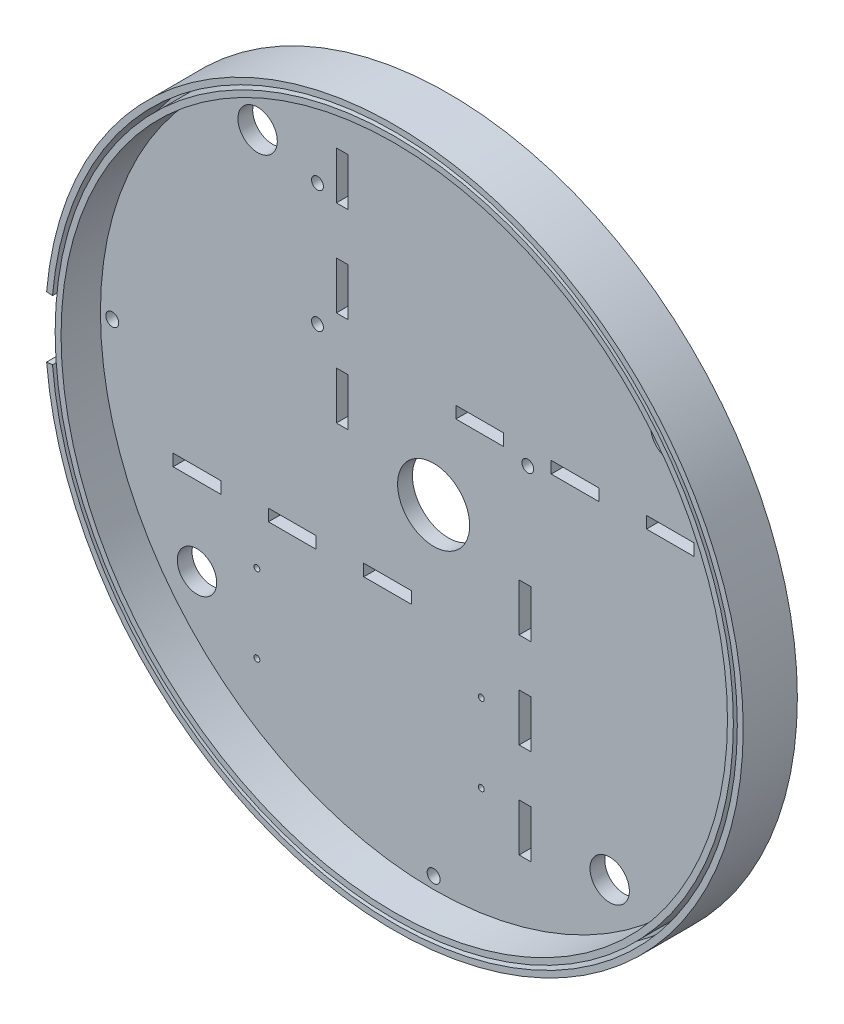
from build123d import *

# Parameters (mm, degrees)
SKETCH1_W                   = 200
SKETCH1_H                   = 200
SKETCH1_R                   = 9.15
BOSS_EXTRUDE1_DEPTH         = 3.75
SKETCH5_W                   = 12.1
SKETCH5_H                   = 3
SKETCH5_R                   = 5
CUT_EXTRUDE6_DEPTH          = 10
CIRPATTERN2_COUNT           = 4
SKETCH6_W                   = 200
SKETCH6_H                   = 200
SKETCH6_R                   = 88.610994186
CUT_EXTRUDE10_DEPTH         = 142.471065946
BOSS_EXTRUDE2_START         = 10
SKETCH7_R                   = 86.110994186
SKETCH7_R_2                 = 84.610994186
BOSS_EXTRUDE2_DEPTH         = 10
SKETCH11_R                  = 1.5
BOSS_EXTRUDE3_DEPTH         = 5
SKETCH13_R                  = 1.5
CUT_EXTRUDE11_DEPTH         = 127.066962688
SKETCH14_R                  = 0.75
BOSS_EXTRUDE4_DEPTH         = 3
SKETCH14_3_R                = 0.75
CUT_EXTRUDE12_DEPTH         = 127.066962688
TAP_DRILL_FOR_M4X0_7_TAP1_D = 3.3
CIRPATTERN3_COUNT           = 4


with BuildPart() as part:
    # Sketch1 → Boss-Extrude1 (new body)
    with BuildSketch(Plane.XY):
        Rectangle(SKETCH1_W, SKETCH1_H)
        Circle(SKETCH1_R, mode=Mode.SUBTRACT)
    extrude(amount=-BOSS_EXTRUDE1_DEPTH)

    # Sketch5 → Cut-Extrude6 (cut)
    with BuildSketch(Plane.XY):
        with Locations((11.7, 23.2)):
            Rectangle(SKETCH5_W, SKETCH5_H)
        with Locations((60.1, 23.2)):
            Rectangle(SKETCH5_W, SKETCH5_H)
        with Locations((35.9, 23.2)):
            Rectangle(SKETCH5_W, SKETCH5_H)
        with Locations((60.1, 44.7)):
            Circle(SKETCH5_R)
    cut_extrude6 = extrude(amount=-CUT_EXTRUDE6_DEPTH, mode=Mode.SUBTRACT)

    # CirPattern2: Cut-Extrude6 ×4 about axis
    cirpattern2_axis = Axis((0, 0, -3.75), (0, 0, 1))
    for i in range(1, CIRPATTERN2_COUNT):
        add(cut_extrude6.rotate(cirpattern2_axis, i * 360 / CIRPATTERN2_COUNT), mode=Mode.SUBTRACT)

    # Sketch6 → Cut-Extrude10 (cut, through all)
    with BuildSketch(Plane.XY):
        Rectangle(SKETCH6_W, SKETCH6_H)
        Circle(SKETCH6_R, mode=Mode.SUBTRACT)
    extrude(amount=-CUT_EXTRUDE10_DEPTH, mode=Mode.SUBTRACT)

    # Sketch7 → Boss-Extrude2 (add)
    # profile 1 of 2: a face of its own
    with BuildSketch(Plane.XY.offset(BOSS_EXTRUDE2_START)):
        Circle(SKETCH7_R)
        Circle(SKETCH7_R_2, mode=Mode.SUBTRACT)
    # profile 2 of 2: a face of its own
    with BuildSketch(Plane.XY.offset(BOSS_EXTRUDE2_START)):
        with BuildLine():
            Line((-88.273802601, 7.722957014), (-86.779510554, 7.5922234))
            ThreePointArc((-86.779510554, 7.5922234), (87.110994186, 0), (-86.779510554, -7.5922234))
            Line((-86.779510554, -7.5922234), (-88.273802601, -7.722957014))
            ThreePointArc((-88.273802601, -7.722957014), (88.610994186, 0), (-88.273802601, 7.722957014))
        make_face()
    extrude(amount=-BOSS_EXTRUDE2_DEPTH)

    # Sketch11 → Boss-Extrude3 (add)
    # profile 1 of 2: a face of its own
    with BuildSketch(Plane(origin=(0, 0, -3.75), x_dir=(-1, 0, 0), z_dir=(0, 0, -1))):
        with BuildLine():
            Line((-26.4, 70.5), (-26.4, 20.5))
            ThreePointArc((-26.4, 20.5), (-23.9, 18), (-21.4, 20.5))
            Line((-21.4, 20.5), (-21.4, 70.5))
            ThreePointArc((-21.4, 70.5), (-23.9, 73), (-26.4, 70.5))
        make_face()
        with Locations((-23.9, 70.5)):
            Circle(SKETCH11_R, mode=Mode.SUBTRACT)
        with Locations((-23.9, 20.5)):
            Circle(SKETCH11_R, mode=Mode.SUBTRACT)
    # profile 2 of 2: a face of its own
    with BuildSketch(Plane(origin=(0, 0, -3.75), x_dir=(-1, 0, 0), z_dir=(0, 0, -1))):
        with BuildLine():
            Line((27, 56), (27, 25))
            ThreePointArc((27, 25), (29.5, 22.5), (32, 25))
            Line((32, 25), (32, 56))
            ThreePointArc((32, 56), (29.5, 58.5), (27, 56))
        make_face()
        with Locations((29.5, 25)):
            Circle(SKETCH11_R, mode=Mode.SUBTRACT)
        with Locations((29.5, 56)):
            Circle(SKETCH11_R, mode=Mode.SUBTRACT)
    extrude(amount=BOSS_EXTRUDE3_DEPTH)

    # Sketch13 → Cut-Extrude11 (cut, through all)
    with BuildSketch(Plane(origin=(0, 0, -3.75), x_dir=(-1, 0, 0), z_dir=(0, 0, -1))):
        with Locations((29.5, 56)):
            Circle(SKETCH13_R)
        with Locations((29.5, 25)):
            Circle(SKETCH13_R)
        with Locations((-23.9, 20.5)):
            Circle(SKETCH13_R)
        with Locations((-23.9, 70.5)):
            Circle(SKETCH13_R)
    extrude(amount=-CUT_EXTRUDE11_DEPTH, mode=Mode.SUBTRACT)

    # Sketch14 → Boss-Extrude4 (add)
    # profile 1 of 2: a face of its own
    with BuildSketch(Plane(origin=(0, 0, -3.75), x_dir=(-1, 0, 0), z_dir=(0, 0, -1))):
        with BuildLine():
            Line((-9.592467607, -56.228581918), (-9.592467607, -36.349902261))
            ThreePointArc((-9.592467607, -36.349902261), (-12.092467607, -33.849902261), (-14.592467607, -36.349902261))
            Line((-14.592467607, -36.349902261), (-14.592467607, -56.228581918))
            ThreePointArc((-14.592467607, -56.228581918), (-12.092467607, -58.728581918), (-9.592467607, -56.228581918))
        make_face()
        with Locations((-12.092467607, -56.228581918)):
            Circle(SKETCH14_R, mode=Mode.SUBTRACT)
        with Locations((-12.092467607, -36.349902261)):
            Circle(SKETCH14_R, mode=Mode.SUBTRACT)
    # profile 2 of 2: a face of its own
    with BuildSketch(Plane(origin=(0, 0, -3.75), x_dir=(-1, 0, 0), z_dir=(0, 0, -1))):
        with BuildLine():
            ThreePointArc((47.38621205, -36.349902261), (44.88621205, -33.849902261), (42.38621205, -36.349902261))
            Line((42.38621205, -36.349902261), (42.38621205, -56.228581918))
            ThreePointArc((42.38621205, -56.228581918), (44.88621205, -58.728581918), (47.38621205, -56.228581918))
            Line((47.38621205, -56.228581918), (47.38621205, -36.349902261))
        make_face()
        with Locations((44.88621205, -56.228581918)):
            Circle(SKETCH14_R, mode=Mode.SUBTRACT)
        with Locations((44.88621205, -36.349902261)):
            Circle(SKETCH14_R, mode=Mode.SUBTRACT)
    extrude(amount=BOSS_EXTRUDE4_DEPTH)

    # Sketch14_3 → Cut-Extrude12 (cut, through all)
    with BuildSketch(Plane(origin=(0, 0, -3.75), x_dir=(-1, 0, 0), z_dir=(0, 0, -1))):
        with Locations((44.88621205, -36.349902261)):
            Circle(SKETCH14_3_R)
        with Locations((-12.092467607, -56.228581918)):
            Circle(SKETCH14_3_R)
        with Locations((-12.092467607, -36.349902261)):
            Circle(SKETCH14_3_R)
        with Locations((44.88621205, -56.228581918)):
            Circle(SKETCH14_3_R)
    extrude(amount=-CUT_EXTRUDE12_DEPTH, mode=Mode.SUBTRACT)

    # Tap Drill for M4x0.7 Tap1 (through all)
    with Locations(Plane.XY):
        with Locations((-81.610994186, 0)):
            tap_drill_for_m4x0_7_tap1 = Hole(TAP_DRILL_FOR_M4X0_7_TAP1_D / 2)

    # CirPattern3: Tap Drill for M4x0.7 Tap1 ×4 about axis
    cirpattern3_axis = Axis((0, 0, 10), (0, 0, 1))
    for i in range(1, CIRPATTERN3_COUNT):
        add(tap_drill_for_m4x0_7_tap1.rotate(cirpattern3_axis, i * 360 / CIRPATTERN3_COUNT), mode=Mode.SUBTRACT)


solid = part.part
